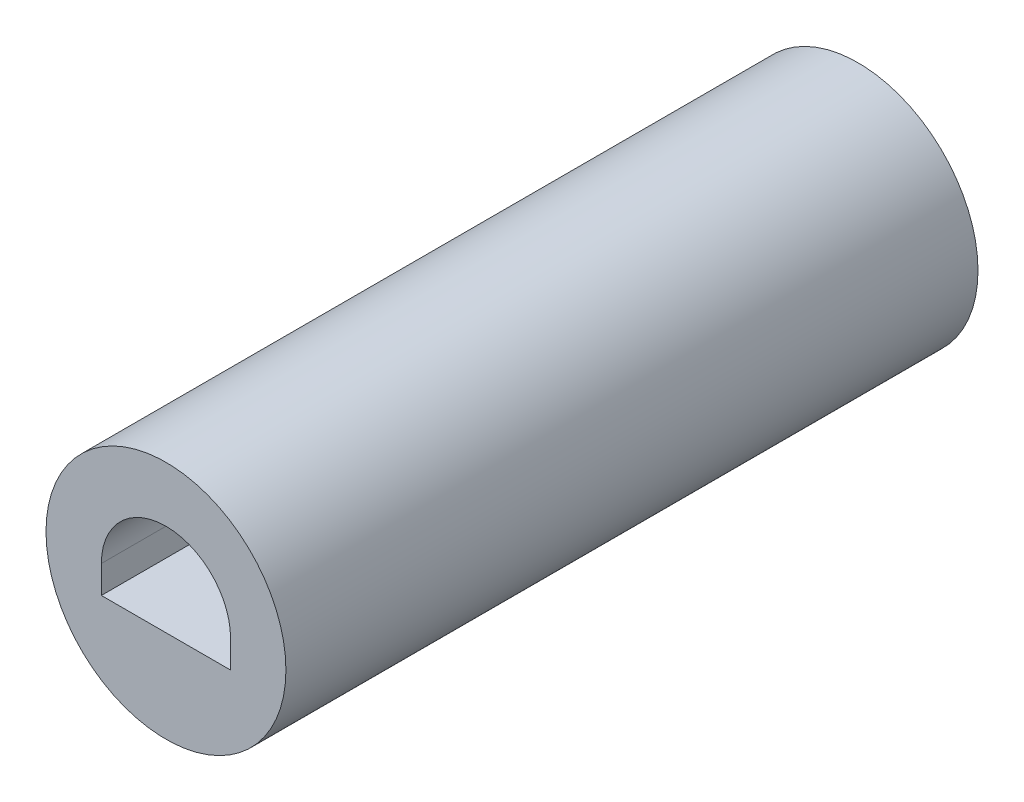
from build123d import *

# Parameters (mm, degrees)
SKETCH1_R           = 1.651
BOSS_EXTRUDE1_DEPTH = 9.525
CUT_EXTRUDE1_DEPTH  = 2.54


with BuildPart() as part:
    # Sketch1 → Boss-Extrude1 (new body)
    with BuildSketch(Plane.XY):
        Circle(SKETCH1_R)
    extrude(amount=BOSS_EXTRUDE1_DEPTH)

    # Sketch2 → Cut-Extrude1 (cut)
    with BuildSketch(Plane.XY.offset(9.525)):
        with BuildLine():
            Line((-0.889, 0), (-0.889, -0.381))
            Line((-0.889, -0.381), (0.7112, -0.381))
            Line((0.7112, -0.381), (0.889, -0.381))
            Line((0.889, -0.381), (0.889, 0))
            ThreePointArc((0.889, 0), (0, 0.889), (-0.889, 0))
        make_face()
    extrude(amount=-CUT_EXTRUDE1_DEPTH, mode=Mode.SUBTRACT)


solid = part.part
